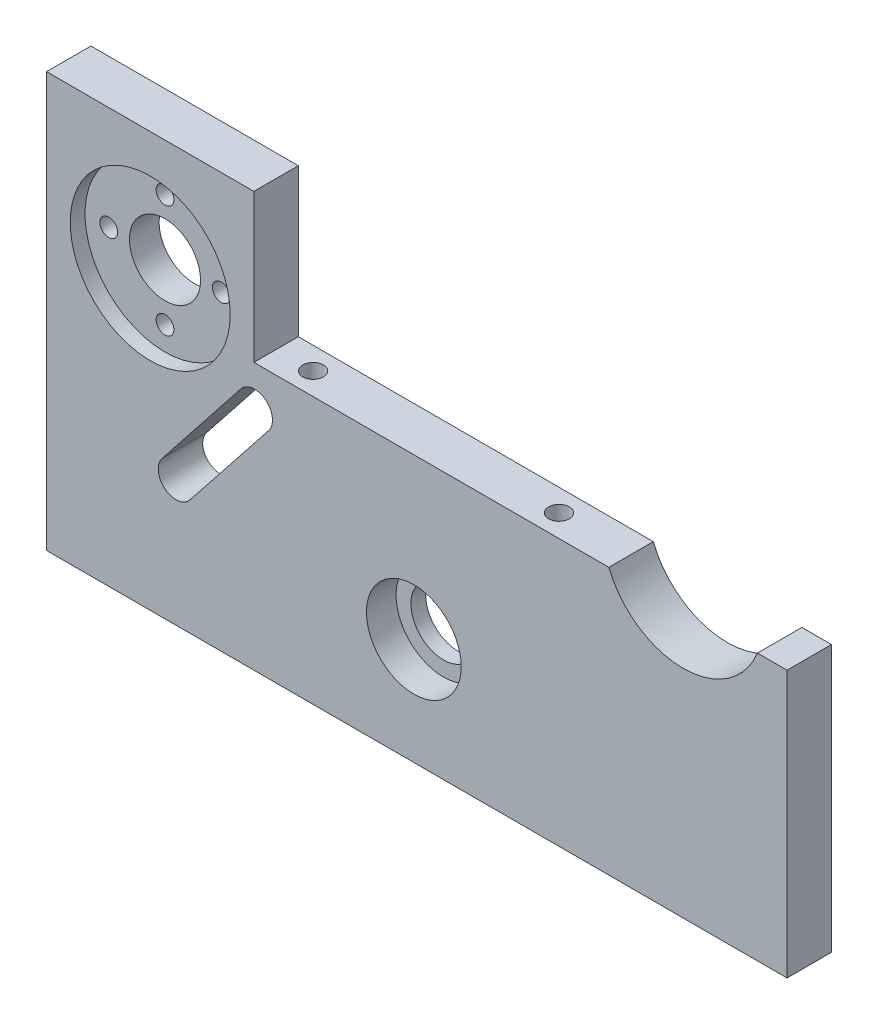
from build123d import *

# Parameters (mm, degrees)
BOSS_EXTRU_1_DEPTH       = 7.5
REPOSE_MOTEUR_DEPTH      = 8
ESQUISSE5_R              = 8
FIXATION_COURROI_1_DEPTH = 5
ESQUISSE6_R              = 5.5
FIXATION_COURROI_2_DEPTH = 2.5
ESQUISSE3_R              = 1.5
ESQUISSE3_R_2            = 6
FIXATION_MOTEUR_1_DEPTH  = 5
ESQUISSE2_R              = 13.5
FIXATION_MOTEUR_2_DEPTH  = 2.5
ESQUISSE9_R              = 1.75
PERCAGE_1_DEPTH          = 7
ESQUISSE7_R              = 1.75
PERCAGE_2_DEPTH          = 7


with BuildPart() as part:
    # Esquisse1 → Boss.-Extru.1 (new body)
    with BuildSketch(Plane.XY):
        Polygon((-53.385579659, 37.671052632), (-53.385579659, -32.328947368), (71.614420341, -32.328947368), (71.614420341, 12.671052632), (-18.385579659, 12.671052632), (-18.385579659, 37.671052632), align=None)
    extrude(amount=BOSS_EXTRU_1_DEPTH)

    # Esquisse4 → Repose moteur (cut)
    with BuildSketch(Plane.XY.offset(7.5)):
        with BuildLine():
            Line((41.534547933, 12.671052632), (66.614420341, 12.671052632))
            ThreePointArc((66.614420341, 12.671052632), (54.074484137, 4.171052632), (41.534547933, 12.671052632))
        make_face()
        with BuildLine():
            Line((-20.599533185, 7.678512609), (-33.878119681, -9.114993842))
            ThreePointArc((-33.878119681, -9.114993842), (-33.385579659, -13.328947368), (-29.171626132, -12.836407346))
            Line((-29.171626132, -12.836407346), (-15.893039636, 3.957099105))
            ThreePointArc((-15.893039636, 3.957099105), (-16.385579659, 8.171052632), (-20.599533185, 7.678512609))
        make_face()
    extrude(amount=-REPOSE_MOTEUR_DEPTH, mode=Mode.SUBTRACT)

    # Esquisse5 → Fixation courroi 1 (cut)
    with BuildSketch(Plane.XY.offset(7.5)):
        with Locations((8.614420341, -14.328947368)):
            Circle(ESQUISSE5_R)
    extrude(amount=-FIXATION_COURROI_1_DEPTH, mode=Mode.SUBTRACT)

    # Esquisse6 → Fixation courroi 2 (cut)
    with BuildSketch(Plane(origin=(0, 0, 0), x_dir=(-1, 0, 0), z_dir=(0, 0, -1))):
        with Locations((-8.614420341, -14.328947368)):
            Circle(ESQUISSE6_R)
    extrude(amount=-FIXATION_COURROI_2_DEPTH, mode=Mode.SUBTRACT)

    # Esquisse3 → Fixation moteur 1 (cut)
    with BuildSketch(Plane(origin=(0, 0, 0), x_dir=(-1, 0, 0), z_dir=(0, 0, -1))):
        with Locations((45.385579659, 17.671052632)):
            Circle(ESQUISSE3_R)
        with Locations((35.885579659, 8.171052632)):
            Circle(ESQUISSE3_R)
        with Locations((26.385579659, 17.671052632)):
            Circle(ESQUISSE3_R)
        with Locations((35.885579659, 27.171052632)):
            Circle(ESQUISSE3_R)
        with Locations((35.885579659, 17.671052632)):
            Circle(ESQUISSE3_R_2)
    extrude(amount=-FIXATION_MOTEUR_1_DEPTH, mode=Mode.SUBTRACT)

    # Esquisse2 → Fixation moteur 2 (cut)
    with BuildSketch(Plane.XY.offset(7.5)):
        with Locations((-35.885579659, 17.671052632)):
            Circle(ESQUISSE2_R)
    extrude(amount=-FIXATION_MOTEUR_2_DEPTH, mode=Mode.SUBTRACT)

    # Esquisse9 → Percage 1 (cut)
    with BuildSketch(Plane(origin=(0, 12.671052632, 0), x_dir=(1, 0, 0), z_dir=(0, 1, 0))):
        with Locations((-12.135579659, -3.75)):
            Circle(ESQUISSE9_R)
        with Locations((29.364420341, -3.75)):
            Circle(ESQUISSE9_R)
    extrude(amount=-PERCAGE_1_DEPTH, mode=Mode.SUBTRACT)

    # Esquisse7 → Percage 2 (cut)
    with BuildSketch(Plane.XZ.offset(32.328947368)):
        with Locations((-49.385579659, 3.800276617)):
            Circle(ESQUISSE7_R)
        with Locations((-17.885579659, 3.800276617)):
            Circle(ESQUISSE7_R)
        with Locations((36.114420341, 3.800276617)):
            Circle(ESQUISSE7_R)
        with Locations((67.614420341, 3.800276617)):
            Circle(ESQUISSE7_R)
    extrude(amount=-PERCAGE_2_DEPTH, mode=Mode.SUBTRACT)


solid = part.part
